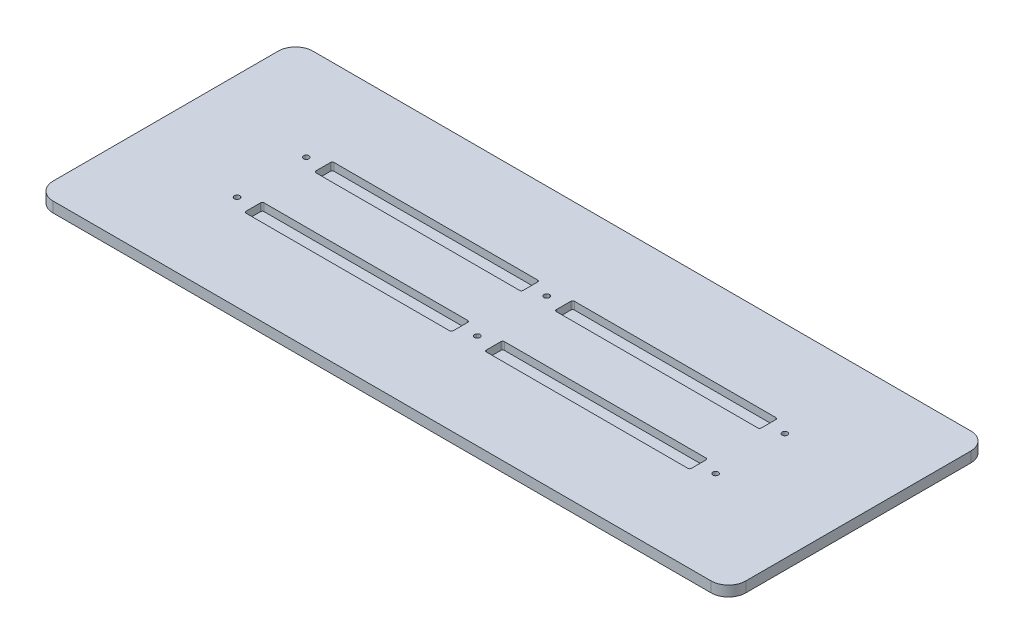
from build123d import *

# Parameters (mm, degrees)
IZIM1_W                     = 400
IZIM1_H                     = 150
Y_KSEKLIK_EKSTR_ZYON1_DEPTH = 6
IZIM2_W                     = 119.6
IZIM2_H                     = 10.4
IZIM2_W_2                   = 118.39
KES_EKSTR_ZYON1_DEPTH       = 4.4
RADYUS1_R                   = 10
IZIM3_R                     = 1.575
KES_EKSTR_ZYON2_DEPTH       = 7
IZIM4_R                     = 2.75
KES_EKSTR_ZYON3_DEPTH       = 2.89
RADYUS2_R                   = 1


with BuildPart() as part:
    # Çizim1 → Yükseklik-Ekstrüzyon1 (new body)
    with BuildSketch(Plane(origin=(0, 0, 0), x_dir=(1, 0, 0), z_dir=(0, 1, 0))):
        Rectangle(IZIM1_W, IZIM1_H)
    extrude(amount=-Y_KSEKLIK_EKSTR_ZYON1_DEPTH)

    # Çizim2 → Kes-Ekstrüzyon1 (cut)
    with BuildSketch(Plane(origin=(0, 0, 0), x_dir=(1, 0, 0), z_dir=(0, 1, 0))):
        with Locations((-69.4, 20.2)):
            Rectangle(IZIM2_W, IZIM2_H)
        with Locations((-69.4, -20.2)):
            Rectangle(IZIM2_W, IZIM2_H)
        with Locations((68.795, 20.2)):
            Rectangle(IZIM2_W_2, IZIM2_H)
        with Locations((68.795, -20.2)):
            Rectangle(IZIM2_W_2, IZIM2_H)
    extrude(amount=-KES_EKSTR_ZYON1_DEPTH, mode=Mode.SUBTRACT)

    # Radyus1
    radyus1_edges = [part.edges().sort_by_distance(p)[0] for p in [
        (200, -3, 75),
        (-200, -3, 75),
        (-200, -3, -75),
        (200, -3, -75),
    ]]
    fillet(radyus1_edges, radius=RADYUS1_R)

    # Çizim3 → Kes-Ekstrüzyon2 (cut, through all)
    with BuildSketch(Plane.XZ.offset(6)):
        with Locations((-138.8, 20)):
            Circle(IZIM3_R)
        with Locations((0, 20)):
            Circle(IZIM3_R)
        with Locations((137.59, 20)):
            Circle(IZIM3_R)
        with Locations((137.59, -20)):
            Circle(IZIM3_R)
        with Locations((0, -20)):
            Circle(IZIM3_R)
        with Locations((-138.8, -20)):
            Circle(IZIM3_R)
    extrude(amount=-KES_EKSTR_ZYON2_DEPTH, mode=Mode.SUBTRACT)

    # Çizim4 → Kes-Ekstrüzyon3 (cut)
    with BuildSketch(Plane.XZ.offset(6)):
        with Locations((-138.8, 20)):
            Circle(IZIM4_R)
        with Locations((0, 20)):
            Circle(IZIM4_R)
        with Locations((137.59, 20)):
            Circle(IZIM4_R)
        with Locations((137.59, -20)):
            Circle(IZIM4_R)
        with Locations((0, -20)):
            Circle(IZIM4_R)
        with Locations((-138.8, -20)):
            Circle(IZIM4_R)
    extrude(amount=-KES_EKSTR_ZYON3_DEPTH, mode=Mode.SUBTRACT)

    # Radyus2
    radyus2_edges = [part.edges().sort_by_distance(p)[0] for p in [
        (127.99, -2.2, -15),
        (9.6, -2.2, -15),
        (9.6, -2.2, -25.4),
        (127.99, -2.2, -25.4),
        (-9.6, -2.2, -25.4),
        (-9.6, -2.2, -15),
        (-129.2, -2.2, -15),
        (-129.2, -2.2, -25.4),
        (127.99, -2.2, 15),
        (127.99, -2.2, 25.4),
        (9.6, -2.2, 25.4),
        (9.6, -2.2, 15),
        (-9.6, -2.2, 15),
        (-9.6, -2.2, 25.4),
        (-129.2, -2.2, 25.4),
        (-129.2, -2.2, 15),
    ]]
    fillet(radyus2_edges, radius=RADYUS2_R)


solid = part.part
